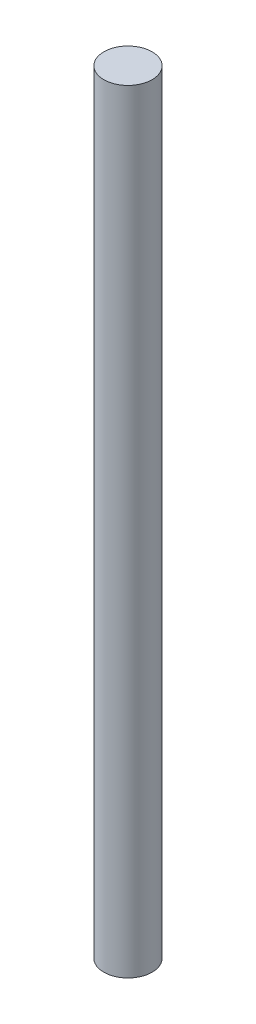
from build123d import *

# Parameters (mm, degrees)
SKETCH1_R           = 3.96875
BOSS_EXTRUDE1_DEPTH = 127


with BuildPart() as part:
    # Sketch1 → Boss-Extrude1 (new body)
    with BuildSketch(Plane(origin=(0, 0, 0), x_dir=(1, 0, 0), z_dir=(0, 1, 0))):
        Circle(SKETCH1_R)
    extrude(amount=BOSS_EXTRUDE1_DEPTH)


solid = part.part
